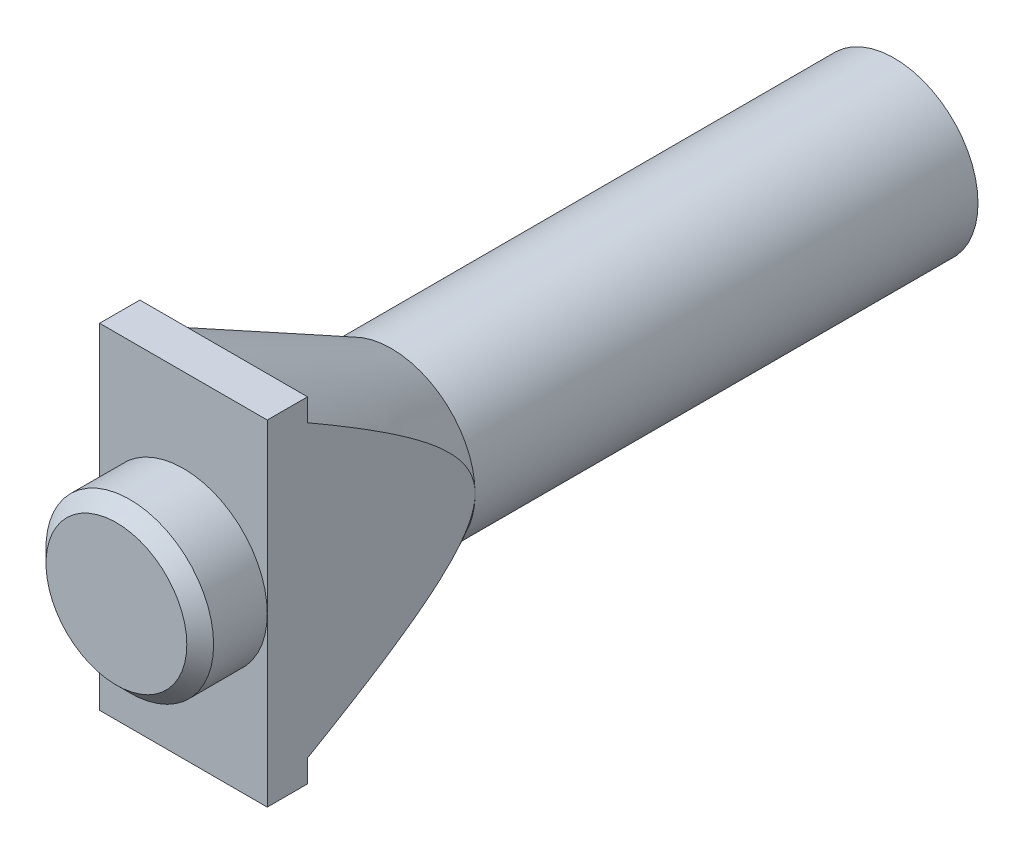
from build123d import *

# Parameters (mm, degrees)
SKETCH1_R           = 6.25
BOSS_EXTRUDE1_DEPTH = 50
SKETCH8_R           = 2.15
CUT_EXTRUDE3_DEPTH  = 25
CUT_EXTRUDE4_DEPTH  = 3.5
SKETCH10_W          = 12.5
SKETCH10_H          = 25
BOSS_EXTRUDE2_DEPTH = 3
SKETCH12_W          = 7.267551801
SKETCH12_H          = 25
SKETCH12_W_2        = 9.375486859
CUT_EXTRUDE5_DEPTH  = 54
SKETCH13_R          = 2.15
CUT_EXTRUDE6_DEPTH  = 25.5
SKETCH14_R          = 6.25
BOSS_EXTRUDE3_DEPTH = 5
CHAMFER1_SIZE       = 1


with BuildPart() as part:
    # Sketch1 → Boss-Extrude1 (new body)
    with BuildSketch(Plane.XY):
        Circle(SKETCH1_R)
    extrude(amount=BOSS_EXTRUDE1_DEPTH)

    # Sketch8 → Cut-Extrude3 (cut)
    with BuildSketch(Plane(origin=(0, 0, 0), x_dir=(-1, 0, 0), z_dir=(0, 0, -1))):
        Circle(SKETCH8_R)
    extrude(amount=-CUT_EXTRUDE3_DEPTH, mode=Mode.SUBTRACT)

    # Sketch9 → Cut-Extrude4 (cut)
    with BuildSketch(Plane(origin=(0, 0, 25), x_dir=(-1, 0, 0), z_dir=(0, 0, -1))):
        Polygon((4.156921938, 0), (2.078460969, 3.6), (-2.078460969, 3.6), (-4.156921938, 0), (-2.078460969, -3.6), (2.078460969, -3.6), align=None)
    extrude(amount=-CUT_EXTRUDE4_DEPTH, mode=Mode.SUBTRACT)

    # Sketch10 → Boss-Extrude2 (add)
    with BuildSketch(Plane.XY.offset(50)):
        Rectangle(SKETCH10_W, SKETCH10_H)
    extrude(amount=BOSS_EXTRUDE2_DEPTH)

    # Sketch11 → Revolve1 (revolve)
    with BuildSketch(Plane(origin=(0, 0, 0), x_dir=(0, 0, -1), z_dir=(1, 0, 0))):
        Polygon((-50, 12.5), (-37.5, 6.25), (-37.5, 0), (-50, 0), align=None)
    revolve(axis=Axis((0, 0, 63.541170981), (0, 0, 1)))

    # Sketch12 → Cut-Extrude5 (cut, through all)
    with BuildSketch(Plane.XY.offset(53)):
        with Locations((-9.883775901, 0)):
            Rectangle(SKETCH12_W, SKETCH12_H)
        with Locations((10.937743429, 0)):
            Rectangle(SKETCH12_W_2, SKETCH12_H)
    extrude(amount=-CUT_EXTRUDE5_DEPTH, mode=Mode.SUBTRACT)

    # Sketch13 → Cut-Extrude6 (cut, through all)
    with BuildSketch(Plane(origin=(0, 0, 28.5), x_dir=(-1, 0, 0), z_dir=(0, 0, -1))):
        Circle(SKETCH13_R)
    extrude(amount=-CUT_EXTRUDE6_DEPTH, mode=Mode.SUBTRACT)

    # Sketch14 → Boss-Extrude3 (add)
    with BuildSketch(Plane.XY.offset(53)):
        Circle(SKETCH14_R)
    extrude(amount=BOSS_EXTRUDE3_DEPTH)

    # Chamfer1
    chamfer1_edges = [part.edges().sort_by_distance(p)[0] for p in [
        (-6.25, 0, 58),
    ]]
    chamfer(chamfer1_edges, length=CHAMFER1_SIZE)


solid = part.part
